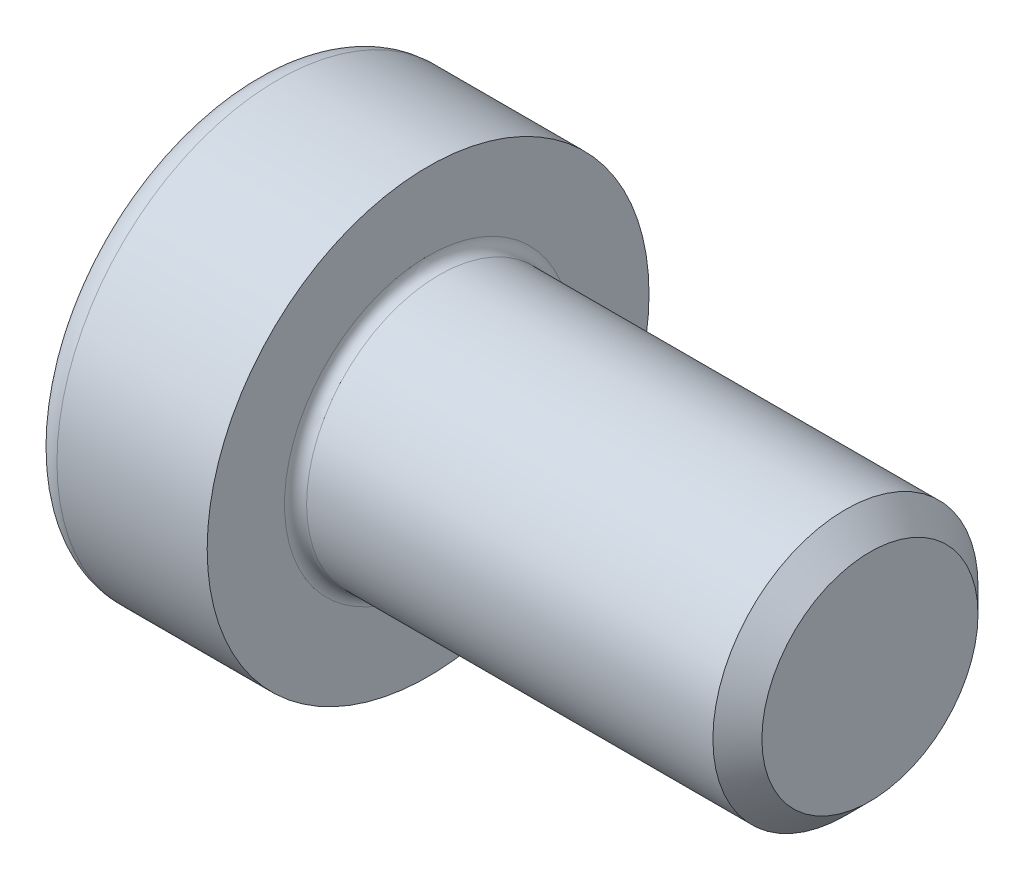
from build123d import *

# Parameters (mm, degrees)
FILLET1_R   = 0.25
FILLET2_R   = 0.6
HEX_2_DEPTH = 3


with BuildPart() as part:
    # BodySke → Base-Revolve (revolve)
    with BuildSketch(Plane.XY, mode=Mode.PRIVATE) as base_revolve_sk:
        Polygon((0, 0), (0, 5), (4, 5), (4, 3), (13.4455, 3), (14, 2.4455), (14, 0), align=None)
    revolve(base_revolve_sk.sketch.rotate(Axis((-31.75, 0, 0), (1, 0, 0)), 90), axis=Axis((-31.75, 0, 0), (1, 0, 0)))  # turned: the seam where the file's is

    # Fillet1
    fillet1_edges = [part.edges().sort_by_distance(p)[0] for p in [
        (4, 0, -3),
    ]]
    fillet(fillet1_edges, radius=FILLET1_R)

    # Fillet2
    fillet2_edges = [part.edges().sort_by_distance(p)[0] for p in [
        (0, 0, -5),
    ]]
    fillet(fillet2_edges, radius=FILLET2_R)

    # Sketch2 → Hex-PreBroach (revolve, cut)
    with BuildSketch(Plane.XY, mode=Mode.PRIVATE) as hex_prebroach_sk:
        Polygon((0, 2), (3, 2), (4.154700538, 0), (0, 0), align=None)
    revolve(hex_prebroach_sk.sketch.rotate(Axis((0, 0, 0), (1, 0, 0)), 90), axis=Axis((0, 0, 0), (1, 0, 0)), mode=Mode.SUBTRACT)  # turned: the seam where the file's is

    # Sketch3 → Hex 2 (cut)
    with BuildSketch(Plane(origin=(0, 0, 0), x_dir=(0, 0.5, 0.866025404), z_dir=(-1, 0, 0))):
        Polygon((1.154700538, 2), (-1.154700538, 2), (-2.309401077, 0), (-1.154700538, -2), (1.154700538, -2), (2.309401077, 0), align=None)
    extrude(amount=-HEX_2_DEPTH, mode=Mode.SUBTRACT)


solid = part.part
